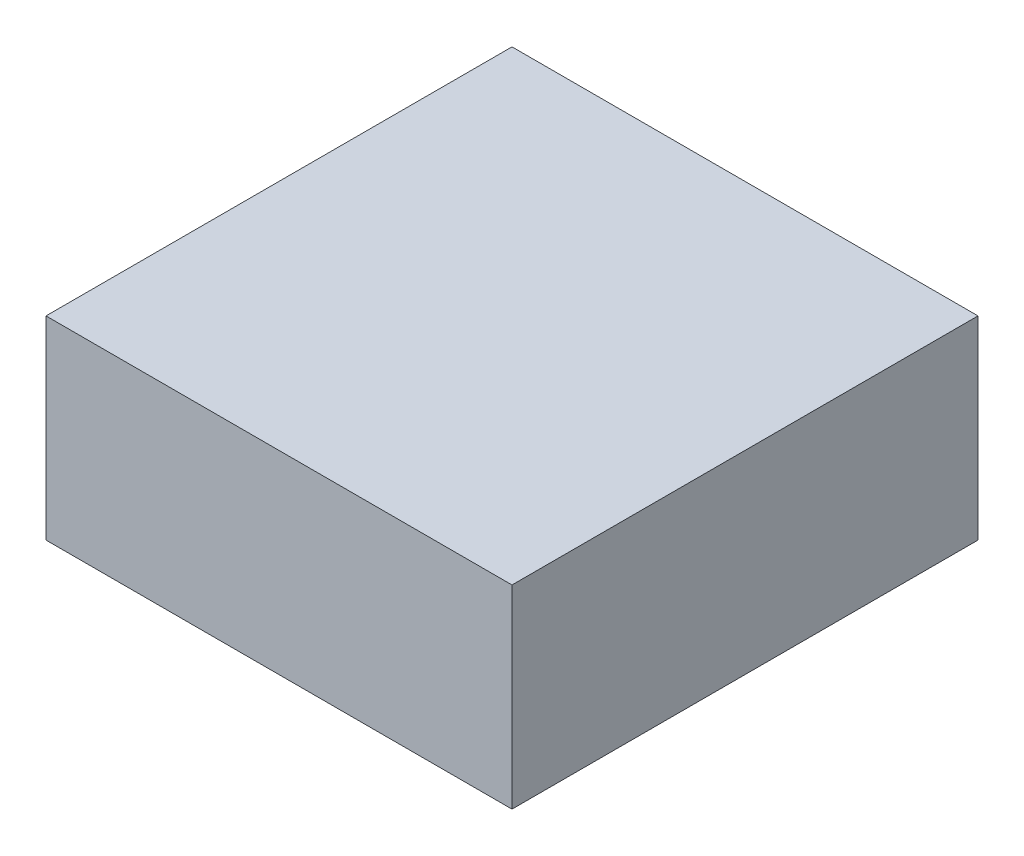
from build123d import *

# Parameters (mm, degrees)
SKETCH_1_W      = 36
SKETCH_1_H      = 36
EXTRUDE_1_DEPTH = 15


with BuildPart() as part:
    # 草图1 → 凸台-拉伸1 (new body)
    with BuildSketch(Plane(origin=(0, 0, 0), x_dir=(1, 0, 0), z_dir=(0, 1, 0))):
        Rectangle(SKETCH_1_W, SKETCH_1_H)
    extrude(amount=EXTRUDE_1_DEPTH)


solid = part.part
